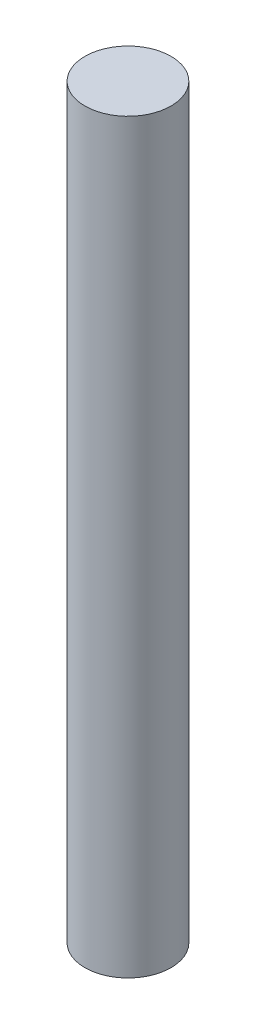
from build123d import *

# Parameters (mm, degrees)
SKETCH1_R           = 0.75
BOSS_EXTRUDE1_DEPTH = 13


with BuildPart() as part:
    # Sketch1 → Boss-Extrude1 (new body)
    with BuildSketch(Plane(origin=(0, 0, 0), x_dir=(1, 0, 0), z_dir=(0, 1, 0))):
        Circle(SKETCH1_R)
    extrude(amount=BOSS_EXTRUDE1_DEPTH)


solid = part.part
